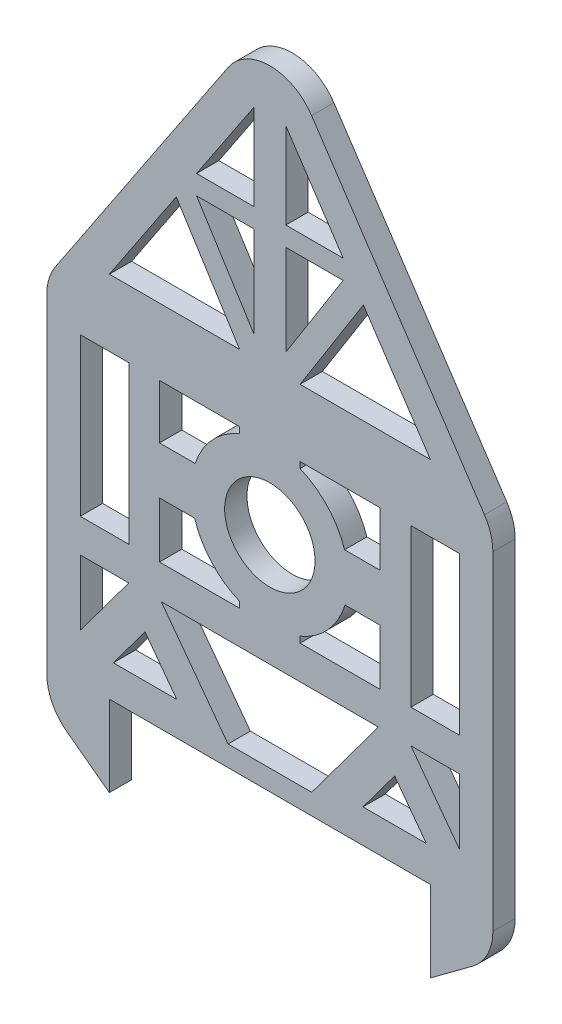
from build123d import *

# Parameters (mm, degrees)
SKETCH1_R           = 40.52203667
BOSS_EXTRUDE1_DEPTH = 20
FILLET1_R           = 45


with BuildPart() as part:
    # Sketch1 → Boss-Extrude1 (new body)
    with BuildSketch(Plane.XY):
        Polygon((-324.500042801, 0), (-36.61106831, 0), (-36.61106831, -72.630227613), (19.444444444, -30.98937664), (19.444444444, 0), (19.444444444, 300), (-180.555555556, 600), (-380.555555556, 300), (-380.555555556, 0), (-380.555555556, -30.98937664), (-324.500042801, -72.630227613), align=None)
        with Locations((-180.555555556, 199.47796333)):
            Circle(SKETCH1_R, mode=Mode.SUBTRACT)
        Polygon((-350.555555556, 98.955926659), (-307.046121917, 98.955926659), (-350.555555556, 40.384990781), align=None, mode=Mode.SUBTRACT)
        Polygon((-218.052993309, 18.381237109), (-277.907920592, 98.955926659), (-83.203190519, 98.955926659), (-143.058117802, 18.381237109), align=None, mode=Mode.SUBTRACT)
        Polygon((-40.212760909, 30), (-97.055418804, 30), (-68.634089856, 68.259836918), align=None, mode=Mode.SUBTRACT)
        Polygon((-350.555555556, 128.955926659), (-307.046121917, 128.955926659), (-307.046121917, 178.791030317), (-307.046121917, 221.457829656), (-307.046121917, 270), (-350.555555556, 270), (-350.555555556, 221.457829656), (-350.555555556, 178.791030317), align=None, mode=Mode.SUBTRACT)
        Polygon((-194.895952536, 524.406135398), (-246.308768225, 447.286911864), (-194.895952536, 447.286911864), align=None, mode=Mode.SUBTRACT)
        Polygon((-36.61106831, 330), (-96.633315679, 420.033371054), (-153.463987032, 330), align=None, mode=Mode.SUBTRACT)
        Polygon((-324.500042801, 330), (-207.64712408, 330), (-264.477795432, 420.033371054), align=None, mode=Mode.SUBTRACT)
        Polygon((-10.555555556, 40.384990781), (-54.064989194, 98.955926659), (-10.555555556, 98.955926659), align=None, mode=Mode.SUBTRACT)
        Polygon((-10.555555556, 128.955926659), (-10.555555556, 178.791030317), (-10.555555556, 221.457829656), (-10.555555556, 270), (-54.064989194, 270), (-54.064989194, 221.457829656), (-54.064989194, 178.791030317), (-54.064989194, 128.955926659), align=None, mode=Mode.SUBTRACT)
        Polygon((-320.898350202, 30), (-264.055692307, 30), (-292.477021255, 68.259836918), align=None, mode=Mode.SUBTRACT)
        with BuildLine():
            Line((-279.511482215, 270), (-279.511482215, 221.457829656))
            Line((-279.511482215, 221.457829656), (-247.564832021, 221.457829656))
            ThreePointArc((-247.564832021, 221.457829656), (-232.312774166, 247.379403578), (-207.64712408, 264.58867344))
            Line((-207.64712408, 264.58867344), (-207.64712408, 270))
            Line((-207.64712408, 270), (-279.511482215, 270))
        make_face(mode=Mode.SUBTRACT)
        with BuildLine():
            Line((-279.511482215, 128.955926659), (-279.511482215, 178.791030317))
            Line((-279.511482215, 178.791030317), (-247.975200012, 178.791030317))
            ThreePointArc((-247.975200012, 178.791030317), (-232.771073725, 152.076514844), (-207.64712408, 134.367253219))
            Line((-207.64712408, 134.367253219), (-207.64712408, 128.955926659))
            Line((-207.64712408, 128.955926659), (-279.511482215, 128.955926659))
        make_face(mode=Mode.SUBTRACT)
        with BuildLine():
            Line((-153.463987032, 134.367253219), (-153.463987032, 128.955926659))
            Line((-153.463987032, 128.955926659), (-81.599628896, 128.955926659))
            Line((-81.599628896, 128.955926659), (-81.599628896, 178.791030317))
            Line((-81.599628896, 178.791030317), (-113.135911099, 178.791030317))
            ThreePointArc((-113.135911099, 178.791030317), (-128.340037386, 152.076514844), (-153.463987032, 134.367253219))
        make_face(mode=Mode.SUBTRACT)
        with BuildLine():
            Line((-153.463987032, 264.58867344), (-153.463987032, 270))
            Line((-153.463987032, 270), (-81.599628896, 270))
            Line((-81.599628896, 270), (-81.599628896, 221.457829656))
            Line((-81.599628896, 221.457829656), (-113.54627909, 221.457829656))
            ThreePointArc((-113.54627909, 221.457829656), (-128.798336945, 247.379403578), (-153.463987032, 264.58867344))
        make_face(mode=Mode.SUBTRACT)
        Polygon((-114.802342886, 429.992241235), (-166.215158575, 429.992241235), (-166.215158575, 348.542048906), align=None, mode=Mode.SUBTRACT)
        Polygon((-114.802342886, 447.286911864), (-166.215158575, 524.406135398), (-166.215158575, 447.286911864), align=None, mode=Mode.SUBTRACT)
        Polygon((-246.308768225, 429.992241235), (-194.895952536, 348.542048906), (-194.895952536, 429.992241235), align=None, mode=Mode.SUBTRACT)
    extrude(amount=BOSS_EXTRUDE1_DEPTH)

    # Fillet1
    fillet1_edges = [part.edges().sort_by_distance(p)[0] for p in [
        (19.444444444, -30.98937664, 10),
        (-380.555555556, -30.98937664, 10),
        (-380.555555556, 300, 10),
        (-180.555555556, 600, 10),
        (19.444444444, 300, 10),
    ]]
    fillet(fillet1_edges, radius=FILLET1_R)


solid = part.part
